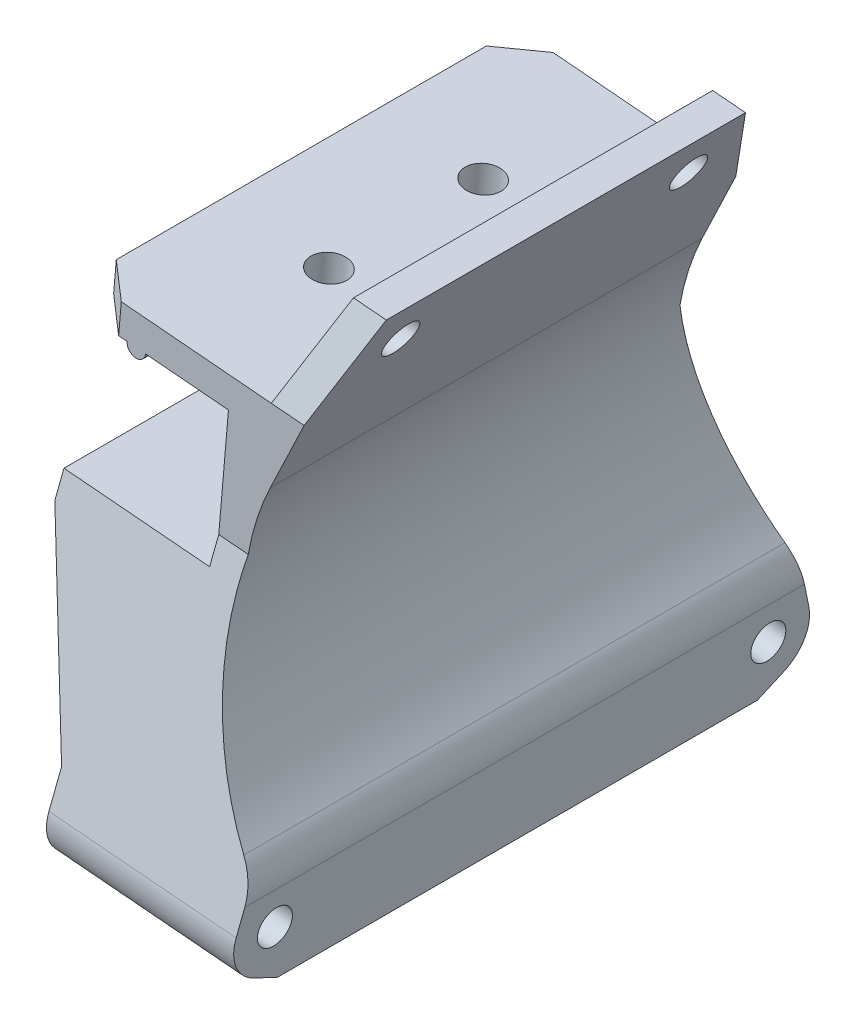
from build123d import *

# Parameters (mm, degrees)
BOSS_EXTRUDE1_DEPTH            = 30
CUT_EXTRUDE1_DEPTH             = 3
CUT_EXTRUDE2_DEPTH             = 60
CUT_EXTRUDE3_DEPTH             = 15
SKETCH7_R                      = 1.75
CUT_EXTRUDE4_DEPTH             = 3
M3X0_5_TAPPED_HOLE1_D          = 2.5
M3X0_5_TAPPED_HOLE1_DEPTH      = 8.5
M3X0_5_TAPPED_HOLE1_TIP        = 0.751075774
M3_CLEARANCE_HOLE1_D           = 3.4
M3_CLEARANCE_HOLE3_D           = 3.4
SKETCH17_R                     = 2.5
CUT_EXTRUDE5_DEPTH             = 21
CUT_EXTRUDE6_REACH             = 51
CUT_EXTRUDE6_DIRECTION_2_DEPTH = 10


with BuildPart() as part:
    # Sketch2 → Boss-Extrude1 (new body, symmetric)
    with BuildSketch(Plane(origin=(13.451769965, -30.26631601, 128.45159414), x_dir=(-0.996309466, 0.085833844, 0), z_dir=(0, 0, -1))):
        with BuildLine():
            Line((34, 0), (34, 8.215390309))
            ThreePointArc((34, 8.215390309), (34.333717374, 10.011443329), (35.290322581, 11.567746711))
            ThreePointArc((35.290322581, 11.567746711), (41.543974558, 24.151766942), (40.336, 38.152))
            Line((40.336, 38.152), (34, 55))
            Line((34, 55), (37.205128205, 55))
            Line((37.205128205, 55), (40.852991453, 45.3))
            Line((40.852991453, 45.3), (59, 45.3))
            Line((59, 45.3), (59, 42.3))
            Line((59, 42.3), (54.677251476, 42.3))
            ThreePointArc((54.677251476, 42.3), (53.777251476, 41.4), (52.877251476, 42.3))
            Line((52.877251476, 42.3), (44.777251476, 42.3))
            Line((44.777251476, 42.3), (44.777251476, 31.3))
            Line((44.777251476, 31.3), (59, 31.3))
            Line((59, 31.3), (59, 26.3))
            Line((59, 26.3), (52.277251476, 9.3))
            Line((52.277251476, 9.3), (52.277251476, 0))
            Line((52.277251476, 0), (34, 0))
        make_face()
    extrude(amount=BOSS_EXTRUDE1_DEPTH, both=True)

    # Sketch3 → Cut-Extrude1 (cut)
    with BuildSketch(Plane(origin=(1.399091662, 16.239844289, 0), x_dir=(0.996309466, -0.085833844, 0), z_dir=(0.085833844, 0.996309466, 0))):
        Polygon((-43, -98.45159414), (-29, -98.45159414), (-43, -110.45159414), align=None)
        Polygon((-43, -146.45159414), (-29, -158.45159414), (-43, -158.45159414), align=None)
    extrude(amount=-CUT_EXTRUDE1_DEPTH, mode=Mode.SUBTRACT)

    # Sketch4 → Cut-Extrude2 (cut)
    with BuildSketch(Plane(origin=(-42.841307019, 3.690855304, 0), x_dir=(0, 0, 1), z_dir=(-0.996309466, 0.085833844, 0))):
        with BuildLine():
            Line((100.589429026, -23.159000176), (107.45159414, 2.3))
            Line((107.45159414, 2.3), (107.45159414, 16.3))
            Line((107.45159414, 16.3), (110.982105413, 26))
            Line((110.982105413, 26), (98.45159414, 26))
            Line((98.45159414, 26), (98.45159414, -29))
            Line((98.45159414, -29), (105.097922488, -29))
            Line((105.097922488, -29), (102.657228442, -27.774947795))
            ThreePointArc((102.657228442, -27.774947795), (100.801138235, -25.835289481), (100.589429026, -23.159000176))
        make_face()
        with BuildLine():
            Line((158.45159414, -29), (158.45159414, 26))
            Line((158.45159414, 26), (145.921082868, 26))
            Line((145.921082868, 26), (149.45159414, 16.3))
            Line((149.45159414, 16.3), (149.45159414, 2.3))
            Line((149.45159414, 2.3), (156.313759254, -23.159000176))
            ThreePointArc((156.313759254, -23.159000176), (156.102050045, -25.835289481), (154.245959839, -27.774947795))
            Line((154.245959839, -27.774947795), (151.805265792, -29))
            Line((151.805265792, -29), (158.45159414, -29))
        make_face()
    extrude(amount=-CUT_EXTRUDE2_DEPTH, mode=Mode.SUBTRACT)

    # Sketch6 → Cut-Extrude3 (cut, symmetric)
    with BuildSketch(Plane(origin=(13.451769965, -30.26631601, 128.45159414), x_dir=(-0.996309466, 0.085833844, 0), z_dir=(0, 0, -1))):
        Polygon((52.277251476, 0), (52.277251476, 2.5), (47.777251476, 0), align=None)
    extrude(amount=CUT_EXTRUDE3_DEPTH, both=True, mode=Mode.SUBTRACT)

    # Sketch7 → Cut-Extrude4 (cut)
    with BuildSketch(Plane(origin=(1.399091662, 16.239844289, 0), x_dir=(0.996309466, -0.085833844, 0), z_dir=(0.085833844, 0.996309466, 0))):
        with Locations((-32.777251476, -135.95159414)):
            Circle(SKETCH7_R)
        with Locations((-32.777251476, -120.95159414)):
            Circle(SKETCH7_R)
    extrude(amount=-CUT_EXTRUDE4_DEPTH, mode=Mode.SUBTRACT)

    # M3x0.5 Tapped Hole1
    with Locations(Plane(origin=(0.197417842, 2.291511771, 0), x_dir=(0.996309466, -0.085833844, 0), z_dir=(0.085833844, 0.996309466, 0))):
        with Locations((-32.777251476, -135.95159414), (-32.777251476, -120.95159414)):
            Hole(M3X0_5_TAPPED_HOLE1_D / 2, depth=M3X0_5_TAPPED_HOLE1_DEPTH)
            with Locations((0, 0, -(M3X0_5_TAPPED_HOLE1_DEPTH + M3X0_5_TAPPED_HOLE1_TIP / 2))):  # 118° drill point
                Cone(0, M3X0_5_TAPPED_HOLE1_D / 2, M3X0_5_TAPPED_HOLE1_TIP, mode=Mode.SUBTRACT)

    # M3 Clearance Hole1 (through all)
    with Locations(Plane(origin=(-36.143369031, 3.113815954, 0), x_dir=(0, 0, 1), z_dir=(-0.996309466, 0.085833844, 0))):
        with Locations((104.45159414, -24.2), (152.45159414, -24.2)):
            Hole(M3_CLEARANCE_HOLE1_D / 2)

    # M3 Clearance Hole3 (through all)
    with Locations(Plane(origin=(-42.841307019, 3.690855304, 0), x_dir=(0, 0, 1), z_dir=(-0.996309466, 0.085833844, 0))):
        with Locations((114.45159414, 21.5), (142.45159414, 21.5)):
            Hole(M3_CLEARANCE_HOLE3_D / 2)

    # Sketch17 → Cut-Extrude5 (cut)
    with BuildSketch(Plane(origin=(-42.841307019, 3.690855304, 0), x_dir=(0, 0, 1), z_dir=(-0.996309466, 0.085833844, 0))):
        with Locations((114.45159414, 21.5)):
            Circle(SKETCH17_R)
        with Locations((142.45159414, 21.5)):
            Circle(SKETCH17_R)
    extrude(amount=-CUT_EXTRUDE5_DEPTH, mode=Mode.SUBTRACT)

    # Cut-Extrude6: up to this face of the body (flat: up to its plane)
    cut_extrude6_end = Plane(part.part.faces().sort_by_distance((-32.038196273, -7.893745722, 152.932561433))[0])
    # Sketch18 → Cut-Extrude6 (cut, up to the picked face)
    with BuildSketch(Plane(origin=(0, 0, 107.45159414), x_dir=(-1, 0, 0), z_dir=(0, 0, -1)), mode=Mode.PRIVATE) as cut_extrude6_sk1:
        Polygon((28.473630197, 4.761573893), (42.643889178, 5.982367075), (42.858473788, 3.491593411), (28.688214808, 2.270800229), align=None)
    cut_extrude6_tool1 = split(extrude(cut_extrude6_sk1.sketch, amount=-CUT_EXTRUDE6_REACH, mode=Mode.PRIVATE), bisect_by=cut_extrude6_end, keep=Keep.BOTH, mode=Mode.PRIVATE)
    add(cut_extrude6_tool1.solids().sort_by_distance((-35.666052, 4.126584, 107.451594))[0], mode=Mode.SUBTRACT)

    # Sketch18 → Cut-Extrude6 direction 2 (cut)
    with BuildSketch(Plane(origin=(0, 0, 107.45159414), x_dir=(-1, 0, 0), z_dir=(0, 0, -1))):
        Polygon((28.473630197, 4.761573893), (42.643889178, 5.982367075), (42.858473788, 3.491593411), (28.688214808, 2.270800229), align=None)
    extrude(amount=CUT_EXTRUDE6_DIRECTION_2_DEPTH, mode=Mode.SUBTRACT)


solid = part.part
